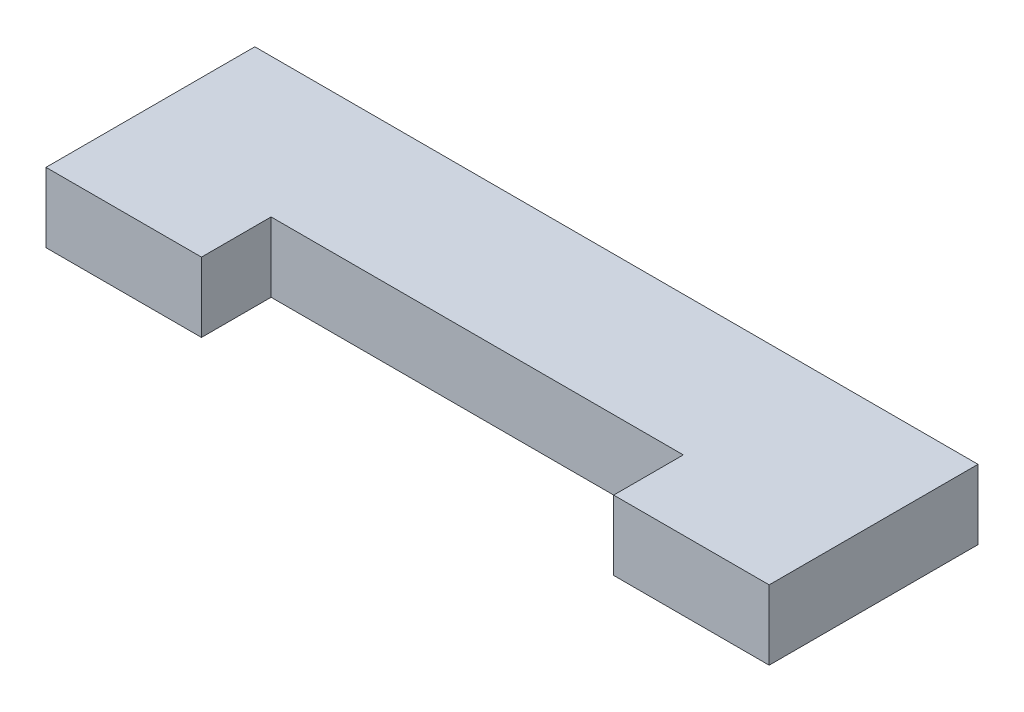
from build123d import *

# Parameters (mm, degrees)
BOSS_EXTRUDE1_DEPTH = 3.85


with BuildPart() as part:
    # Sketch1 → Boss-Extrude1 (new body)
    with BuildSketch(Plane(origin=(0, 0, 0), x_dir=(1, 0, 0), z_dir=(0, 1, 0))):
        Polygon((-20, -3.85), (-20, -7.7), (-11.4, -7.7), (-11.4, -3.85), (11.4, -3.85), (11.4, -7.7), (20, -7.7), (20, -3.85), (20, 3.85), (-20, 3.85), align=None)
    extrude(amount=BOSS_EXTRUDE1_DEPTH)


solid = part.part
